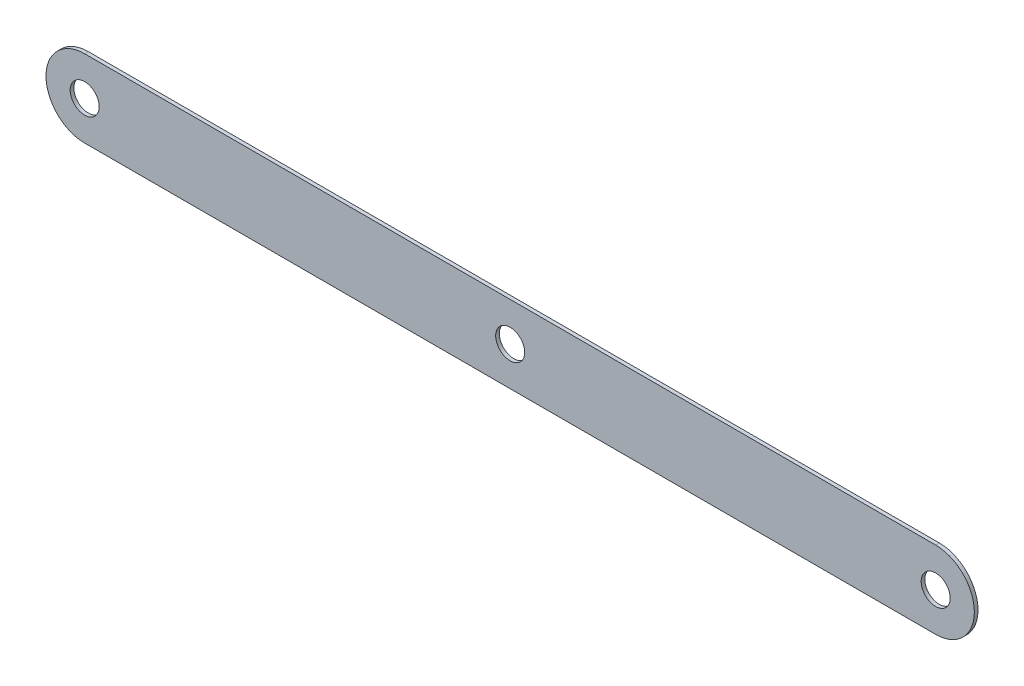
from build123d import *

# Parameters (mm, degrees)
SKETCH1_W           = 279.4
SKETCH1_H           = 25.4
BOSS_EXTRUDE1_DEPTH = 1.2
SKETCH2_R           = 4.7625
CUT_EXTRUDE1_DEPTH  = 2.2
SKETCH3_R           = 4.7625
CUT_EXTRUDE2_DEPTH  = 2.2


with BuildPart() as part:
    # Sketch1 → Boss-Extrude1 (new body)
    with BuildSketch(Plane.XY):
        Rectangle(SKETCH1_W, SKETCH1_H)
        with BuildLine():
            ThreePointArc((139.7, 12.7), (152.4, 0), (139.7, -12.7))
            Line((139.7, -12.7), (139.7, 12.7))
        make_face()
        with BuildLine():
            Line((-139.7, 12.7), (-139.7, -12.7))
            ThreePointArc((-139.7, -12.7), (-152.4, 0), (-139.7, 12.7))
        make_face()
    extrude(amount=BOSS_EXTRUDE1_DEPTH)

    # Sketch2 → Cut-Extrude1 (cut, through all)
    with BuildSketch(Plane.XY.offset(1.2)):
        Circle(SKETCH2_R)
    extrude(amount=-CUT_EXTRUDE1_DEPTH, mode=Mode.SUBTRACT)

    # Sketch3 → Cut-Extrude2 (cut, through all)
    with BuildSketch(Plane.XY.offset(1.2)):
        with Locations((-139.7, 0)):
            Circle(SKETCH3_R)
        with Locations((139.7, 0)):
            Circle(SKETCH3_R)
    extrude(amount=-CUT_EXTRUDE2_DEPTH, mode=Mode.SUBTRACT)


solid = part.part
